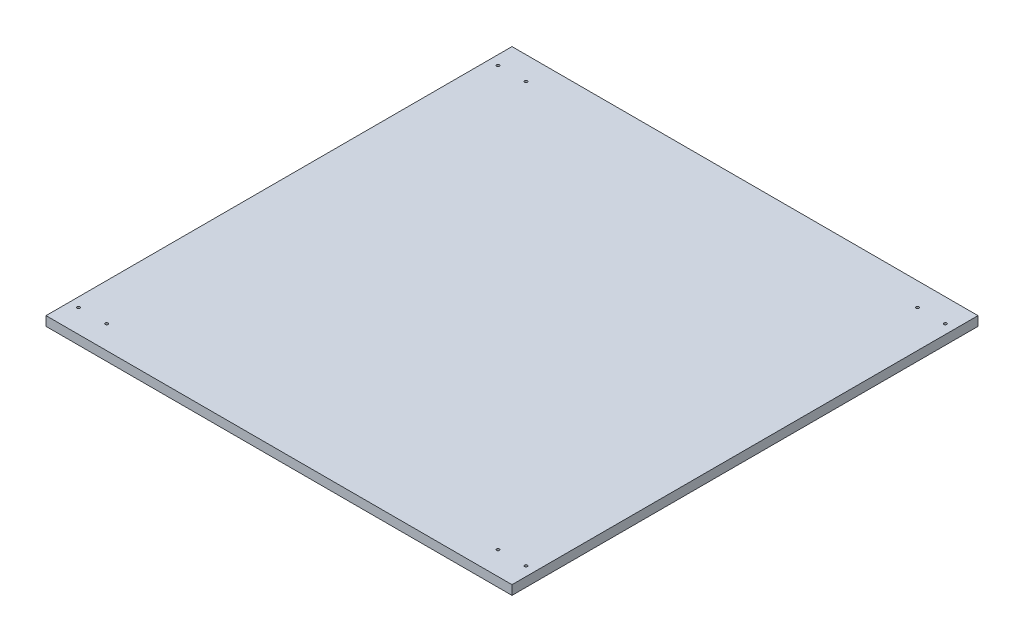
from build123d import *

# Parameters (mm, degrees)
SKETCH1_W           = 500
SKETCH1_H           = 500
BOSS_EXTRUDE1_DEPTH = 10
SKETCH2_R           = 1.5
CUT_EXTRUDE1_DEPTH  = 10


with BuildPart() as part:
    # Sketch1 → Boss-Extrude1 (new body)
    with BuildSketch(Plane(origin=(0, 0, 0), x_dir=(1, 0, 0), z_dir=(0, 1, 0))):
        with Locations((250, 250)):
            Rectangle(SKETCH1_W, SKETCH1_H)
    extrude(amount=BOSS_EXTRUDE1_DEPTH)

    # Sketch2 → Cut-Extrude1 (cut)
    with BuildSketch(Plane(origin=(0, 10, 0), x_dir=(1, 0, 0), z_dir=(0, 1, 0))):
        with Locations((10, 25)):
            Circle(SKETCH2_R)
        with Locations((10, 475)):
            Circle(SKETCH2_R)
        with Locations((40, 475)):
            Circle(SKETCH2_R)
        with Locations((40, 25)):
            Circle(SKETCH2_R)
        with Locations((460, 475)):
            Circle(SKETCH2_R)
        with Locations((490, 475)):
            Circle(SKETCH2_R)
        with Locations((460, 25)):
            Circle(SKETCH2_R)
        with Locations((490, 25)):
            Circle(SKETCH2_R)
    extrude(amount=-CUT_EXTRUDE1_DEPTH, mode=Mode.SUBTRACT)


solid = part.part
